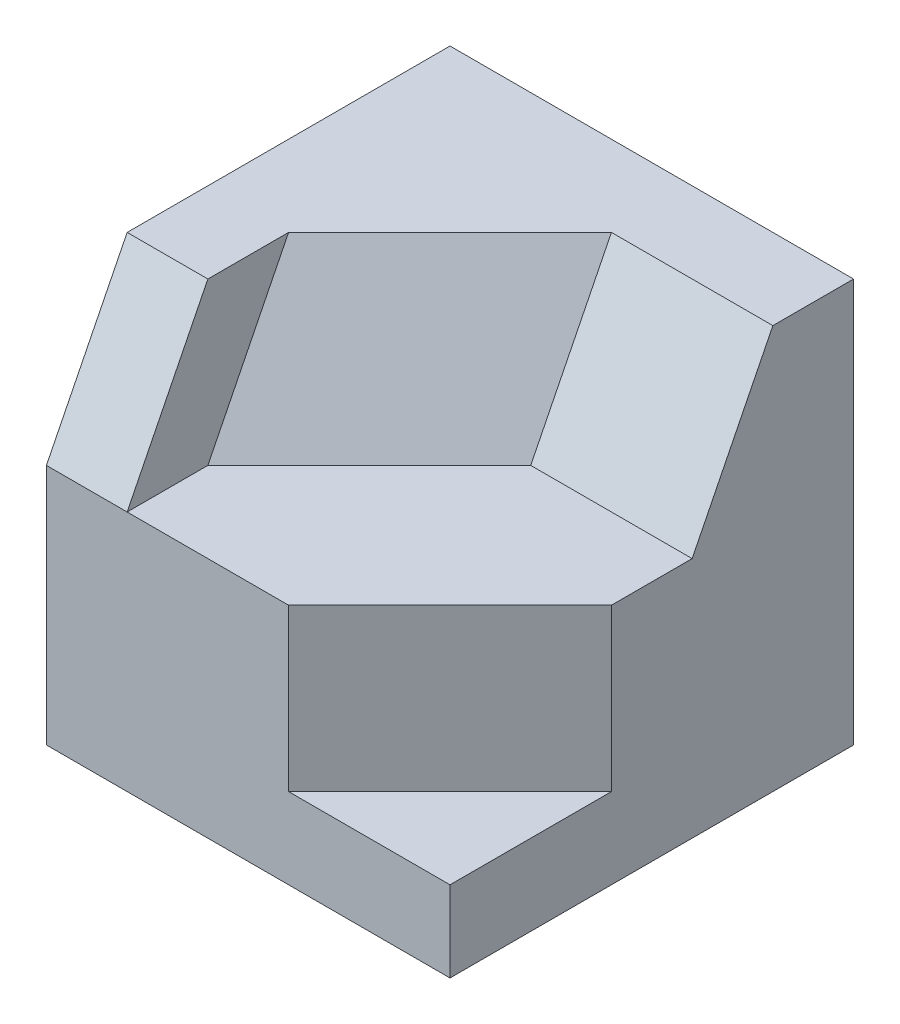
from build123d import *

# Parameters (mm, degrees)
SKETCH1_W           = 5
SKETCH1_H           = 5
BOSS_EXTRUDE1_DEPTH = 5
CUT_EXTRUDE1_DEPTH  = 4
CUT_EXTRUDE2_DEPTH  = 1
SKETCH5_W           = 2
SKETCH5_H           = 2
CUT_EXTRUDE9_DEPTH  = 3
CUT_EXTRUDE10_DEPTH = 2
SKETCH11_W          = 1
SKETCH11_H          = 2
CUT_EXTRUDE11_DEPTH = 2
CUT_EXTRUDE14_DEPTH = 5
CUT_EXTRUDE15_DEPTH = 2
CUT_EXTRUDE16_DEPTH = 2


with BuildPart() as part:
    # Sketch1 → Boss-Extrude1 (new body)
    with BuildSketch(Plane.XY):
        Rectangle(SKETCH1_W, SKETCH1_H)
    extrude(amount=BOSS_EXTRUDE1_DEPTH)

    # Sketch2 → Cut-Extrude1 (cut)
    with BuildSketch(Plane(origin=(0, 2.5, 0), x_dir=(1, 0, 0), z_dir=(0, 1, 0))):
        Polygon((2.5, -5), (2.5, -3), (0.5, -5), align=None)
    extrude(amount=-CUT_EXTRUDE1_DEPTH, mode=Mode.SUBTRACT)

    # Sketch4 → Cut-Extrude2 (cut)
    with BuildSketch(Plane.ZY.offset(2.5)):
        Polygon((5, 2.5), (4, 2.5), (5, 0.5), align=None)
    extrude(amount=-CUT_EXTRUDE2_DEPTH, mode=Mode.SUBTRACT)

    # Sketch5 → Cut-Extrude9 (cut)
    with BuildSketch(Plane.XY.offset(5)):
        with Locations((1.5, 1.5)):
            Rectangle(SKETCH5_W, SKETCH5_H)
    extrude(amount=-CUT_EXTRUDE9_DEPTH, mode=Mode.SUBTRACT)

    # Sketch10 → Cut-Extrude10 (cut)
    with BuildSketch(Plane(origin=(2.5, 0, 0), x_dir=(0, 0, -1), z_dir=(1, 0, 0))):
        Polygon((-1, 2.5), (-2, 0.5), (-2, 2.5), align=None)
    extrude(amount=-CUT_EXTRUDE10_DEPTH, mode=Mode.SUBTRACT)

    # Sketch11 → Cut-Extrude11 (cut)
    with BuildSketch(Plane(origin=(0.5, 0, 0), x_dir=(0, 0, -1), z_dir=(1, 0, 0))):
        with Locations((-4.5, 1.5)):
            Rectangle(SKETCH11_W, SKETCH11_H)
    extrude(amount=-CUT_EXTRUDE11_DEPTH, mode=Mode.SUBTRACT)

    # Sketch16 → Cut-Extrude14 (cut, through all)
    with BuildSketch(Plane(origin=(1.222222222, 0.611111111, 1.222222222), x_dir=(-0.745355992, 0.298142397, 0.596284794), z_dir=(-0.666666667, -0.333333333, -0.666666667))):
        Polygon((0.96896279, -0.447213595), (0.96896279, 1.788854382), (3.652244363, 0.894427191), (3.652244363, -1.341640786), align=None)
    extrude(amount=-CUT_EXTRUDE14_DEPTH, mode=Mode.SUBTRACT)

    # Sketch17 → Cut-Extrude15 (cut)
    with BuildSketch(Plane(origin=(-1.5, 0, 0), x_dir=(0, 0, -1), z_dir=(1, 0, 0))):
        Polygon((-3, 2.5), (-4, 0.5), (-4, 2.5), align=None)
    extrude(amount=CUT_EXTRUDE15_DEPTH, mode=Mode.SUBTRACT)

    # Sketch18 → Cut-Extrude16 (cut)
    with BuildSketch(Plane(origin=(0, 0.5, 0), x_dir=(1, 0, 0), z_dir=(0, 1, 0))):
        Polygon((0.5, -4), (0.5, -2), (-1.5, -4), align=None)
    extrude(amount=CUT_EXTRUDE16_DEPTH, mode=Mode.SUBTRACT)


solid = part.part
